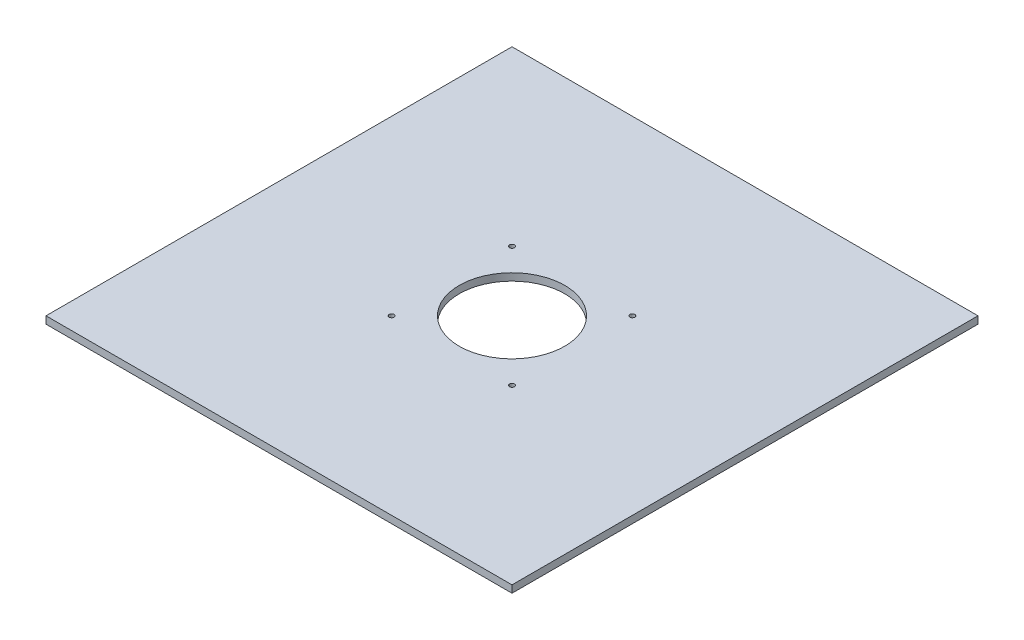
from build123d import *

# Parameters (mm, degrees)
SKETCH1_W           = 406.4
SKETCH1_H           = 406.4
BOSS_EXTRUDE1_DEPTH = 6.35
CUT_EXTRUDE1_REACH  = 8.35
SKETCH2_R           = 46
SKETCH2_R_2         = 2.15
SKETCH2_R_3         = 2.165


with BuildPart() as part:
    # Sketch1 → Boss-Extrude1 (new body)
    with BuildSketch(Plane(origin=(0, 0, 0), x_dir=(1, 0, 0), z_dir=(0, 1, 0))):
        Rectangle(SKETCH1_W, SKETCH1_H)
    extrude(amount=BOSS_EXTRUDE1_DEPTH)

    # Sketch2 → Cut-Extrude1 (cut, up to next)
    with BuildSketch(Plane(origin=(0, 6.35, 0), x_dir=(1, 0, 0), z_dir=(0, 1, 0)), mode=Mode.PRIVATE) as cut_extrude1_sk1:
        Circle(SKETCH2_R)
    cut_extrude1_tool1 = extrude(cut_extrude1_sk1.sketch, amount=-CUT_EXTRUDE1_REACH, mode=Mode.PRIVATE) & part.part
    add(cut_extrude1_tool1.solids().sort_by_distance((0, 6.35, 0))[0], mode=Mode.SUBTRACT)
    # Sketch2 → Cut-Extrude1 (cut, up to next)
    with BuildSketch(Plane(origin=(0, 6.35, 0), x_dir=(1, 0, 0), z_dir=(0, 1, 0)), mode=Mode.PRIVATE) as cut_extrude1_sk2:
        with Locations((52.5, 52.5)):
            Circle(SKETCH2_R_2)
    cut_extrude1_tool2 = extrude(cut_extrude1_sk2.sketch, amount=-CUT_EXTRUDE1_REACH, mode=Mode.PRIVATE) & part.part
    add(cut_extrude1_tool2.solids().sort_by_distance((52.5, 6.35, -52.5))[0], mode=Mode.SUBTRACT)
    # Sketch2 → Cut-Extrude1 (cut, up to next)
    with BuildSketch(Plane(origin=(0, 6.35, 0), x_dir=(1, 0, 0), z_dir=(0, 1, 0)), mode=Mode.PRIVATE) as cut_extrude1_sk3:
        with Locations((52.5, -52.5)):
            Circle(SKETCH2_R_2)
    cut_extrude1_tool3 = extrude(cut_extrude1_sk3.sketch, amount=-CUT_EXTRUDE1_REACH, mode=Mode.PRIVATE) & part.part
    add(cut_extrude1_tool3.solids().sort_by_distance((52.5, 6.35, 52.5))[0], mode=Mode.SUBTRACT)
    # Sketch2 → Cut-Extrude1 (cut, up to next)
    with BuildSketch(Plane(origin=(0, 6.35, 0), x_dir=(1, 0, 0), z_dir=(0, 1, 0)), mode=Mode.PRIVATE) as cut_extrude1_sk4:
        with Locations((-52.5, -52.5)):
            Circle(SKETCH2_R_2)
    cut_extrude1_tool4 = extrude(cut_extrude1_sk4.sketch, amount=-CUT_EXTRUDE1_REACH, mode=Mode.PRIVATE) & part.part
    add(cut_extrude1_tool4.solids().sort_by_distance((-52.5, 6.35, 52.5))[0], mode=Mode.SUBTRACT)
    # Sketch2 → Cut-Extrude1 (cut, up to next)
    with BuildSketch(Plane(origin=(0, 6.35, 0), x_dir=(1, 0, 0), z_dir=(0, 1, 0)), mode=Mode.PRIVATE) as cut_extrude1_sk5:
        with Locations((-52.5, 52.5)):
            Circle(SKETCH2_R_3)
    cut_extrude1_tool5 = extrude(cut_extrude1_sk5.sketch, amount=-CUT_EXTRUDE1_REACH, mode=Mode.PRIVATE) & part.part
    add(cut_extrude1_tool5.solids().sort_by_distance((-52.5, 6.35, -52.5))[0], mode=Mode.SUBTRACT)


solid = part.part
